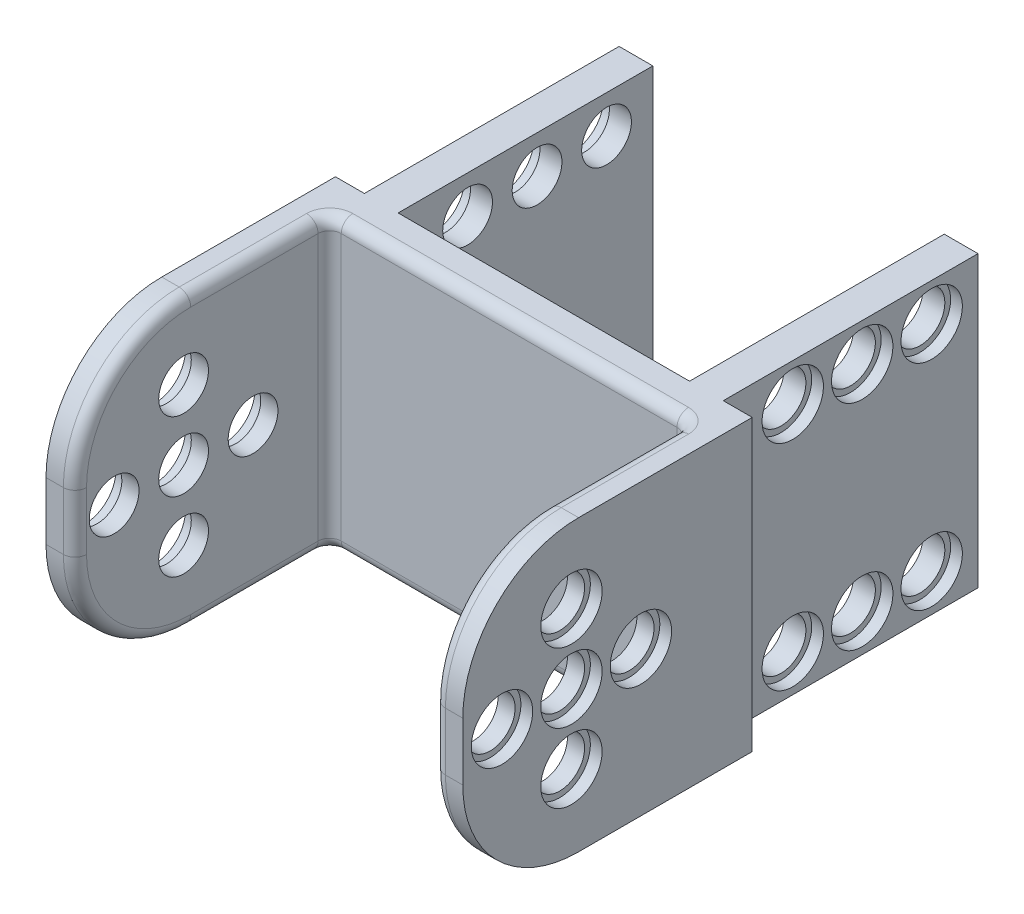
from build123d import *

# Parameters (mm, degrees)
CROQUIS1_W              = 36
CROQUIS1_H              = 25
SALIENTE_EXTRUIR1_DEPTH = 25
CROQUIS2_W              = 31
CROQUIS2_H              = 25
CORTAR_EXTRUIR1_DEPTH   = 22
CROQUIS3_R              = 2.15
CORTAR_EXTRUIR2_DEPTH   = 51.457903246
CROQUIS3_3_R            = 2.65
CROQUIS3_3_R_2          = 2.15
CORTAR_EXTRUIR3_DEPTH   = 1.015
CORTAR_EXTRUIR4_START   = -1.015
CROQUIS4_R              = 2.65
CROQUIS4_R_2            = 2.15
CORTAR_EXTRUIR4_DEPTH   = 1.015
CROQUIS5_W              = 31
CROQUIS5_H              = 25
SALIENTE_EXTRUIR2_DEPTH = 22
CROQUIS6_W              = 25.17
CROQUIS6_H              = 25
CORTAR_EXTRUIR5_DEPTH   = 22
CROQUIS8_R              = 2.15
CORTAR_EXTRUIR6_DEPTH   = 49.705749147
CROQUIS8_3_R            = 2.65
CROQUIS8_3_R_2          = 2.15
CORTAR_EXTRUIR7_DEPTH   = 1.015
CORTAR_EXTRUIR8_START   = -1.015
CROQUIS10_R             = 2.65
CROQUIS10_R_2           = 2.15
CORTAR_EXTRUIR8_DEPTH   = 1.015
REDONDEO2_R             = 10
REDONDEO3_R             = 1
REDONDEO4_R             = 1
REDONDEO5_R             = 1


with BuildPart() as part:
    # Croquis1 → Saliente-Extruir1 (new body)
    with BuildSketch(Plane.XY):
        with Locations((18, 12.5)):
            Rectangle(CROQUIS1_W, CROQUIS1_H)
    extrude(amount=SALIENTE_EXTRUIR1_DEPTH)

    # Croquis2 → Cortar-Extruir1 (cut)
    with BuildSketch(Plane.XY.offset(25)):
        with Locations((18, 12.5)):
            Rectangle(CROQUIS2_W, CROQUIS2_H)
    extrude(amount=-CORTAR_EXTRUIR1_DEPTH, mode=Mode.SUBTRACT)

    # Croquis3 → Cortar-Extruir2 (cut, through all)
    with BuildSketch(Plane(origin=(36, 0, 0), x_dir=(0, 0, -1), z_dir=(1, 0, 0))):
        with Locations((-15.615366346, 18.5)):
            Circle(CROQUIS3_R)
        with Locations((-9.615366346, 12.5)):
            Circle(CROQUIS3_R)
        with Locations((-21.615366346, 12.5)):
            Circle(CROQUIS3_R)
        with Locations((-15.615366346, 6.5)):
            Circle(CROQUIS3_R)
        with Locations((-15.615366346, 12.5)):
            Circle(CROQUIS3_R)
    extrude(amount=-CORTAR_EXTRUIR2_DEPTH, mode=Mode.SUBTRACT)

    # Croquis3_3 → Cortar-Extruir3 (cut)
    # profile 1 of 5: a face of its own
    with BuildSketch(Plane(origin=(36, 0, 0), x_dir=(0, 0, -1), z_dir=(1, 0, 0))):
        with Locations((-15.615366346, 18.5)):
            Circle(CROQUIS3_3_R)
        with Locations((-15.615366346, 18.5)):
            Circle(CROQUIS3_3_R_2, mode=Mode.SUBTRACT)
    # profile 2 of 5: a face of its own
    with BuildSketch(Plane(origin=(36, 0, 0), x_dir=(0, 0, -1), z_dir=(1, 0, 0))):
        with Locations((-9.615366346, 12.5)):
            Circle(CROQUIS3_3_R)
        with Locations((-9.615366346, 12.5)):
            Circle(CROQUIS3_3_R_2, mode=Mode.SUBTRACT)
    # profile 3 of 5: a face of its own
    with BuildSketch(Plane(origin=(36, 0, 0), x_dir=(0, 0, -1), z_dir=(1, 0, 0))):
        with Locations((-21.615366346, 12.5)):
            Circle(CROQUIS3_3_R)
        with Locations((-21.615366346, 12.5)):
            Circle(CROQUIS3_3_R_2, mode=Mode.SUBTRACT)
    # profile 4 of 5: a face of its own
    with BuildSketch(Plane(origin=(36, 0, 0), x_dir=(0, 0, -1), z_dir=(1, 0, 0))):
        with Locations((-15.615366346, 6.5)):
            Circle(CROQUIS3_3_R)
        with Locations((-15.615366346, 6.5)):
            Circle(CROQUIS3_3_R_2, mode=Mode.SUBTRACT)
    # profile 5 of 5: a face of its own
    with BuildSketch(Plane(origin=(36, 0, 0), x_dir=(0, 0, -1), z_dir=(1, 0, 0))):
        with Locations((-15.615366346, 12.5)):
            Circle(CROQUIS3_3_R)
        with Locations((-15.615366346, 12.5)):
            Circle(CROQUIS3_3_R_2, mode=Mode.SUBTRACT)
    extrude(amount=-CORTAR_EXTRUIR3_DEPTH, mode=Mode.SUBTRACT)

    # Croquis4 → Cortar-Extruir4 (cut)
    # profile 1 of 5: a face of its own
    with BuildSketch(Plane.ZY.offset(CORTAR_EXTRUIR4_START)):
        with Locations((15.615366346, 18.5)):
            Circle(CROQUIS4_R)
        with Locations((15.615366346, 18.5)):
            Circle(CROQUIS4_R_2, mode=Mode.SUBTRACT)
    # profile 2 of 5: a face of its own
    with BuildSketch(Plane.ZY.offset(CORTAR_EXTRUIR4_START)):
        with Locations((21.615366346, 12.5)):
            Circle(CROQUIS4_R)
        with Locations((21.615366346, 12.5)):
            Circle(CROQUIS4_R_2, mode=Mode.SUBTRACT)
    # profile 3 of 5: a face of its own
    with BuildSketch(Plane.ZY.offset(CORTAR_EXTRUIR4_START)):
        with Locations((15.615366346, 6.5)):
            Circle(CROQUIS4_R)
        with Locations((15.615366346, 6.5)):
            Circle(CROQUIS4_R_2, mode=Mode.SUBTRACT)
    # profile 4 of 5: a face of its own
    with BuildSketch(Plane.ZY.offset(CORTAR_EXTRUIR4_START)):
        with Locations((15.615366346, 12.5)):
            Circle(CROQUIS4_R)
        with Locations((15.615366346, 12.5)):
            Circle(CROQUIS4_R_2, mode=Mode.SUBTRACT)
    # profile 5 of 5: a face of its own
    with BuildSketch(Plane.ZY.offset(CORTAR_EXTRUIR4_START)):
        with Locations((9.615366346, 12.5)):
            Circle(CROQUIS4_R)
        with Locations((9.615366346, 12.5)):
            Circle(CROQUIS4_R_2, mode=Mode.SUBTRACT)
    extrude(amount=CORTAR_EXTRUIR4_DEPTH, mode=Mode.SUBTRACT)

    # Croquis5 → Saliente-Extruir2 (add)
    with BuildSketch(Plane(origin=(0, 0, 0), x_dir=(-1, 0, 0), z_dir=(0, 0, -1))):
        with Locations((-18, 12.5)):
            Rectangle(CROQUIS5_W, CROQUIS5_H)
    extrude(amount=SALIENTE_EXTRUIR2_DEPTH)

    # Croquis6 → Cortar-Extruir5 (cut)
    with BuildSketch(Plane(origin=(0, 0, -22), x_dir=(-1, 0, 0), z_dir=(0, 0, -1))):
        with Locations((-18, 12.5)):
            Rectangle(CROQUIS6_W, CROQUIS6_H)
    extrude(amount=-CORTAR_EXTRUIR5_DEPTH, mode=Mode.SUBTRACT)

    # Croquis8 → Cortar-Extruir6 (cut, through all)
    with BuildSketch(Plane.ZY.offset(-2.5)):
        with Locations((-18, 21.75)):
            Circle(CROQUIS8_R)
        with Locations((-12, 21.75)):
            Circle(CROQUIS8_R)
        with Locations((-6, 21.75)):
            Circle(CROQUIS8_R)
        with Locations((-18, 3.25)):
            Circle(CROQUIS8_R)
        with Locations((-12, 3.25)):
            Circle(CROQUIS8_R)
        with Locations((-6, 3.25)):
            Circle(CROQUIS8_R)
    extrude(amount=-CORTAR_EXTRUIR6_DEPTH, mode=Mode.SUBTRACT)

    # Croquis8_3 → Cortar-Extruir7 (cut)
    # profile 1 of 6: a face of its own
    with BuildSketch(Plane.ZY.offset(-2.5)):
        with Locations((-6, 21.75)):
            Circle(CROQUIS8_3_R)
        with Locations((-6, 21.75)):
            Circle(CROQUIS8_3_R_2, mode=Mode.SUBTRACT)
    # profile 2 of 6: a face of its own
    with BuildSketch(Plane.ZY.offset(-2.5)):
        with Locations((-18, 21.75)):
            Circle(CROQUIS8_3_R)
        with Locations((-18, 21.75)):
            Circle(CROQUIS8_3_R_2, mode=Mode.SUBTRACT)
    # profile 3 of 6: a face of its own
    with BuildSketch(Plane.ZY.offset(-2.5)):
        with Locations((-6, 3.25)):
            Circle(CROQUIS8_3_R)
        with Locations((-6, 3.25)):
            Circle(CROQUIS8_3_R_2, mode=Mode.SUBTRACT)
    # profile 4 of 6: a face of its own
    with BuildSketch(Plane.ZY.offset(-2.5)):
        with Locations((-18, 3.25)):
            Circle(CROQUIS8_3_R)
        with Locations((-18, 3.25)):
            Circle(CROQUIS8_3_R_2, mode=Mode.SUBTRACT)
    # profile 5 of 6: a face of its own
    with BuildSketch(Plane.ZY.offset(-2.5)):
        with Locations((-12, 21.75)):
            Circle(CROQUIS8_3_R)
        with Locations((-12, 21.75)):
            Circle(CROQUIS8_3_R_2, mode=Mode.SUBTRACT)
    # profile 6 of 6: a face of its own
    with BuildSketch(Plane.ZY.offset(-2.5)):
        with Locations((-12, 3.25)):
            Circle(CROQUIS8_3_R)
        with Locations((-12, 3.25)):
            Circle(CROQUIS8_3_R_2, mode=Mode.SUBTRACT)
    extrude(amount=-CORTAR_EXTRUIR7_DEPTH, mode=Mode.SUBTRACT)

    # Croquis10 → Cortar-Extruir8 (cut)
    # profile 1 of 6: a face of its own
    with BuildSketch(Plane(origin=(33.5, 0, 0), x_dir=(0, 0, -1), z_dir=(1, 0, 0)).offset(CORTAR_EXTRUIR8_START)):
        with Locations((6, 21.75)):
            Circle(CROQUIS10_R)
        with Locations((6, 21.75)):
            Circle(CROQUIS10_R_2, mode=Mode.SUBTRACT)
    # profile 2 of 6: a face of its own
    with BuildSketch(Plane(origin=(33.5, 0, 0), x_dir=(0, 0, -1), z_dir=(1, 0, 0)).offset(CORTAR_EXTRUIR8_START)):
        with Locations((18, 21.75)):
            Circle(CROQUIS10_R)
        with Locations((18, 21.75)):
            Circle(CROQUIS10_R_2, mode=Mode.SUBTRACT)
    # profile 3 of 6: a face of its own
    with BuildSketch(Plane(origin=(33.5, 0, 0), x_dir=(0, 0, -1), z_dir=(1, 0, 0)).offset(CORTAR_EXTRUIR8_START)):
        with Locations((6, 3.25)):
            Circle(CROQUIS10_R)
        with Locations((6, 3.25)):
            Circle(CROQUIS10_R_2, mode=Mode.SUBTRACT)
    # profile 4 of 6: a face of its own
    with BuildSketch(Plane(origin=(33.5, 0, 0), x_dir=(0, 0, -1), z_dir=(1, 0, 0)).offset(CORTAR_EXTRUIR8_START)):
        with Locations((18, 3.25)):
            Circle(CROQUIS10_R)
        with Locations((18, 3.25)):
            Circle(CROQUIS10_R_2, mode=Mode.SUBTRACT)
    # profile 5 of 6: a face of its own
    with BuildSketch(Plane(origin=(33.5, 0, 0), x_dir=(0, 0, -1), z_dir=(1, 0, 0)).offset(CORTAR_EXTRUIR8_START)):
        with Locations((12, 3.25)):
            Circle(CROQUIS10_R)
        with Locations((12, 3.25)):
            Circle(CROQUIS10_R_2, mode=Mode.SUBTRACT)
    # profile 6 of 6: a face of its own
    with BuildSketch(Plane(origin=(33.5, 0, 0), x_dir=(0, 0, -1), z_dir=(1, 0, 0)).offset(CORTAR_EXTRUIR8_START)):
        with Locations((12, 21.75)):
            Circle(CROQUIS10_R)
        with Locations((12, 21.75)):
            Circle(CROQUIS10_R_2, mode=Mode.SUBTRACT)
    extrude(amount=CORTAR_EXTRUIR8_DEPTH, mode=Mode.SUBTRACT)

    # Redondeo2
    redondeo2_edges = [part.edges().sort_by_distance(p)[0] for p in [
        (1.25, 0, 25),
        (34.75, 0, 25),
        (34.75, 25, 25),
        (1.25, 25, 25),
    ]]
    fillet(redondeo2_edges, radius=REDONDEO2_R)

    # Redondeo3
    redondeo3_edges = [part.edges().sort_by_distance(p)[0] for p in [
        (33.5, 12.5, 3),
    ]]
    fillet(redondeo3_edges, radius=REDONDEO3_R)

    # Redondeo4
    redondeo4_edges = [part.edges().sort_by_distance(p)[0] for p in [
        (2.5, 12.5, 3),
    ]]
    fillet(redondeo4_edges, radius=REDONDEO4_R)

    # Redondeo5
    redondeo5_edges = [part.edges().sort_by_distance(p)[0] for p in [
        (2.792893219, 0, 3.292893219),
        (2.5, 0, 9.5),
        (2.5, 2.928932188, 22.071067812),
        (2.5, 12.5, 25),
        (2.5, 22.071067812, 22.071067812),
        (2.5, 25, 9.5),
        (2.792893219, 25, 3.292893219),
        (33.207106781, 25, 3.292893219),
        (33.5, 25, 9.5),
        (33.5, 22.071067812, 22.071067812),
        (33.5, 12.5, 25),
        (33.5, 2.928932188, 22.071067812),
        (33.5, 0, 9.5),
        (33.207106781, 0, 3.292893219),
        (18, 25, 3),
        (18, 0, 3),
    ]]
    fillet(redondeo5_edges, radius=REDONDEO5_R)


solid = part.part
